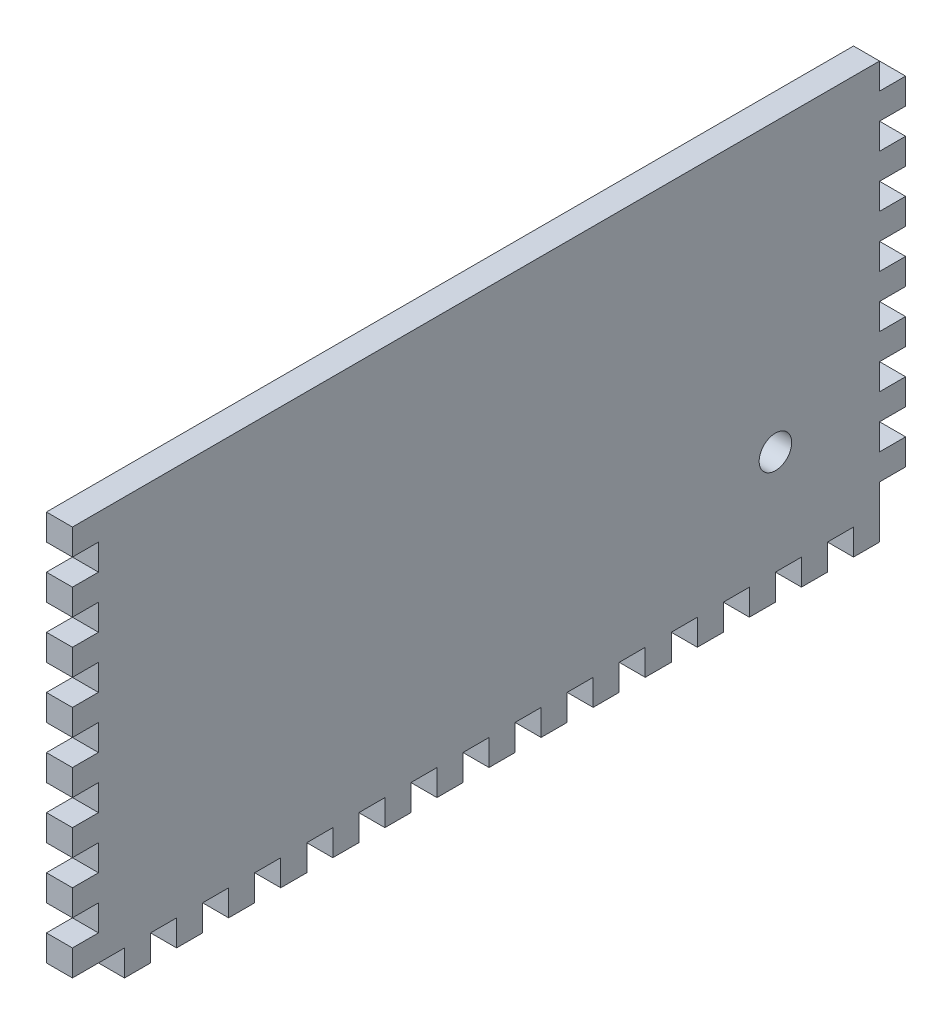
from build123d import *

# Parameters (mm, degrees)
SKETCH1_W           = 203.2
SKETCH1_H           = 101.6
BOSS_EXTRUDE1_DEPTH = 6.35
SKETCH3_W           = 6.35
SKETCH3_H           = 12.7
CUT_EXTRUDE2_DEPTH  = 6.35
SKETCH4_W           = 6.35
SKETCH4_H           = 6.35
CUT_EXTRUDE3_DEPTH  = 6.35
LPATTERN1_COUNT     = 15
LPATTERN1_PITCH     = 12.7
SKETCH5_W           = 6.35
SKETCH5_H           = 6.35
CUT_EXTRUDE4_DEPTH  = 6.35
LPATTERN2_COUNT     = 7
LPATTERN2_PITCH     = 12.7
SKETCH6_W           = 6.35
SKETCH6_H           = 6.35
CUT_EXTRUDE5_DEPTH  = 6.35
SKETCH8_W           = 6.35
SKETCH8_H           = 6.35
CUT_EXTRUDE6_DEPTH  = 6.35
LPATTERN3_COUNT     = 7
LPATTERN3_PITCH     = 12.7
SKETCH9_R           = 3.96875
CUT_EXTRUDE7_DEPTH  = 6.35


with BuildPart() as part:
    # Sketch1 → Boss-Extrude1 (new body)
    with BuildSketch(Plane(origin=(0, 0, 0), x_dir=(0, 0, -1), z_dir=(1, 0, 0))):
        with Locations((101.6, 50.8)):
            Rectangle(SKETCH1_W, SKETCH1_H)
    extrude(amount=BOSS_EXTRUDE1_DEPTH)

    # Sketch3 → Cut-Extrude2 (cut)
    with BuildSketch(Plane.XZ):
        with Locations((3.175, -6.35)):
            Rectangle(SKETCH3_W, SKETCH3_H)
    extrude(amount=-CUT_EXTRUDE2_DEPTH, mode=Mode.SUBTRACT)

    # Sketch4 → Cut-Extrude3 (cut)
    with BuildSketch(Plane.XZ):
        with Locations((3.175, -22.225)):
            Rectangle(SKETCH4_W, SKETCH4_H)
    cut_extrude3 = extrude(amount=-CUT_EXTRUDE3_DEPTH, mode=Mode.SUBTRACT)

    # LPattern1: Cut-Extrude3 ×15
    with Locations(*[(0, 0, -i * LPATTERN1_PITCH) for i in range(1, LPATTERN1_COUNT)]):
        add(cut_extrude3, mode=Mode.SUBTRACT)

    # Sketch5 → Cut-Extrude4 (cut)
    with BuildSketch(Plane.XY):
        with Locations((3.175, 15.875)):
            Rectangle(SKETCH5_W, SKETCH5_H)
    cut_extrude4 = extrude(amount=-CUT_EXTRUDE4_DEPTH, mode=Mode.SUBTRACT)

    # LPattern2: Cut-Extrude4 ×7
    with Locations(*[(0, i * LPATTERN2_PITCH, 0) for i in range(1, LPATTERN2_COUNT)]):
        add(cut_extrude4, mode=Mode.SUBTRACT)

    # Sketch6 → Cut-Extrude5 (cut)
    with BuildSketch(Plane(origin=(0, 0, -203.2), x_dir=(-1, 0, 0), z_dir=(0, 0, -1))):
        with Locations((-3.175, 9.525)):
            Rectangle(SKETCH6_W, SKETCH6_H)
    extrude(amount=-CUT_EXTRUDE5_DEPTH, mode=Mode.SUBTRACT)

    # Sketch8 → Cut-Extrude6 (cut)
    with BuildSketch(Plane(origin=(0, 0, -203.2), x_dir=(-1, 0, 0), z_dir=(0, 0, -1))):
        with Locations((-3.175, 22.225)):
            Rectangle(SKETCH8_W, SKETCH8_H)
    cut_extrude6 = extrude(amount=-CUT_EXTRUDE6_DEPTH, mode=Mode.SUBTRACT)

    # LPattern3: Cut-Extrude6 ×7
    with Locations(*[(0, i * LPATTERN3_PITCH, 0) for i in range(1, LPATTERN3_COUNT)]):
        add(cut_extrude6, mode=Mode.SUBTRACT)

    # Sketch9 → Cut-Extrude7 (cut)
    with BuildSketch(Plane.ZY):
        with Locations((-171.45, 31.75)):
            Circle(SKETCH9_R)
    extrude(amount=-CUT_EXTRUDE7_DEPTH, mode=Mode.SUBTRACT)


solid = part.part
